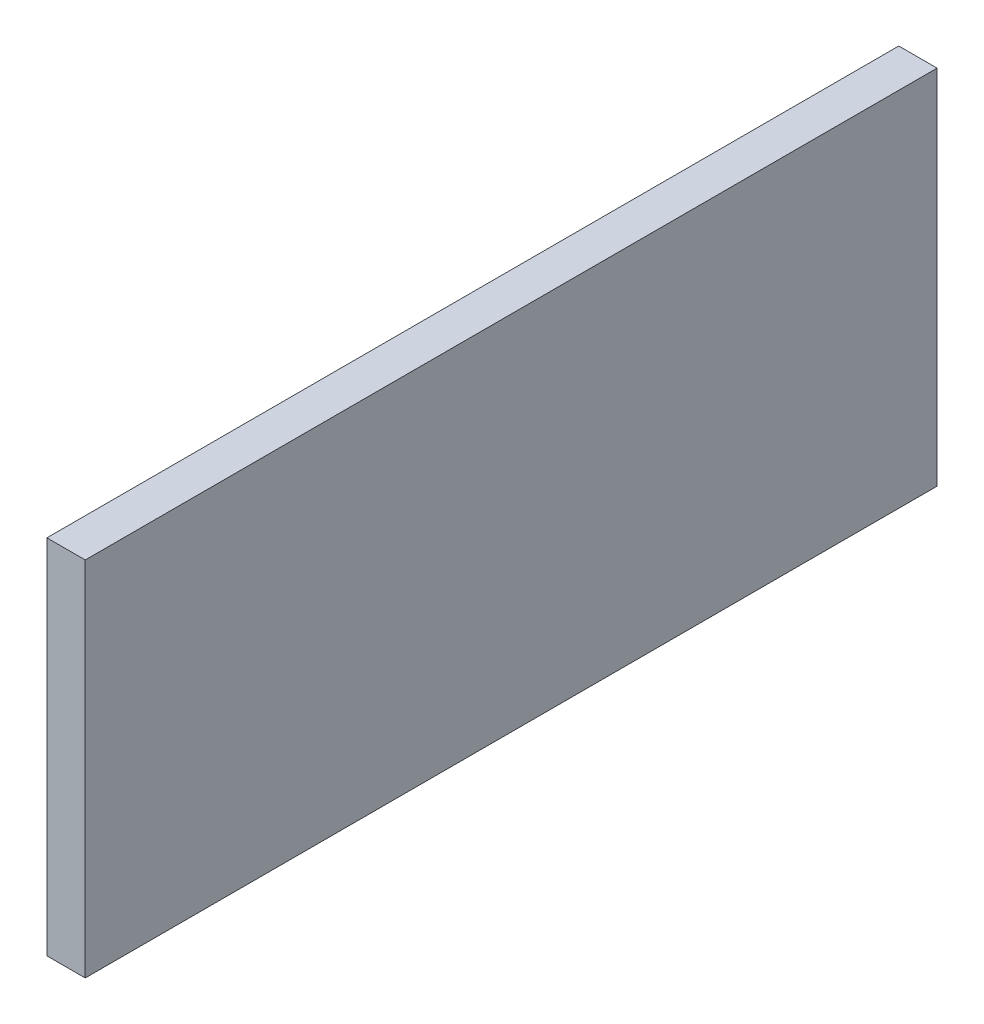
from build123d import *

# Parameters (mm, degrees)
SKETCH_1_W      = 400
SKETCH_1_H      = 170
EXTRUDE_1_DEPTH = 18


with BuildPart() as part:
    # Эскиз1 → Бобышка-Вытянуть1 (new body)
    with BuildSketch(Plane(origin=(0, 0, 0), x_dir=(0, 0, -1), z_dir=(1, 0, 0))):
        with Locations((160.231840454, -66.247783891)):
            Rectangle(SKETCH_1_W, SKETCH_1_H)
    extrude(amount=EXTRUDE_1_DEPTH)


solid = part.part
